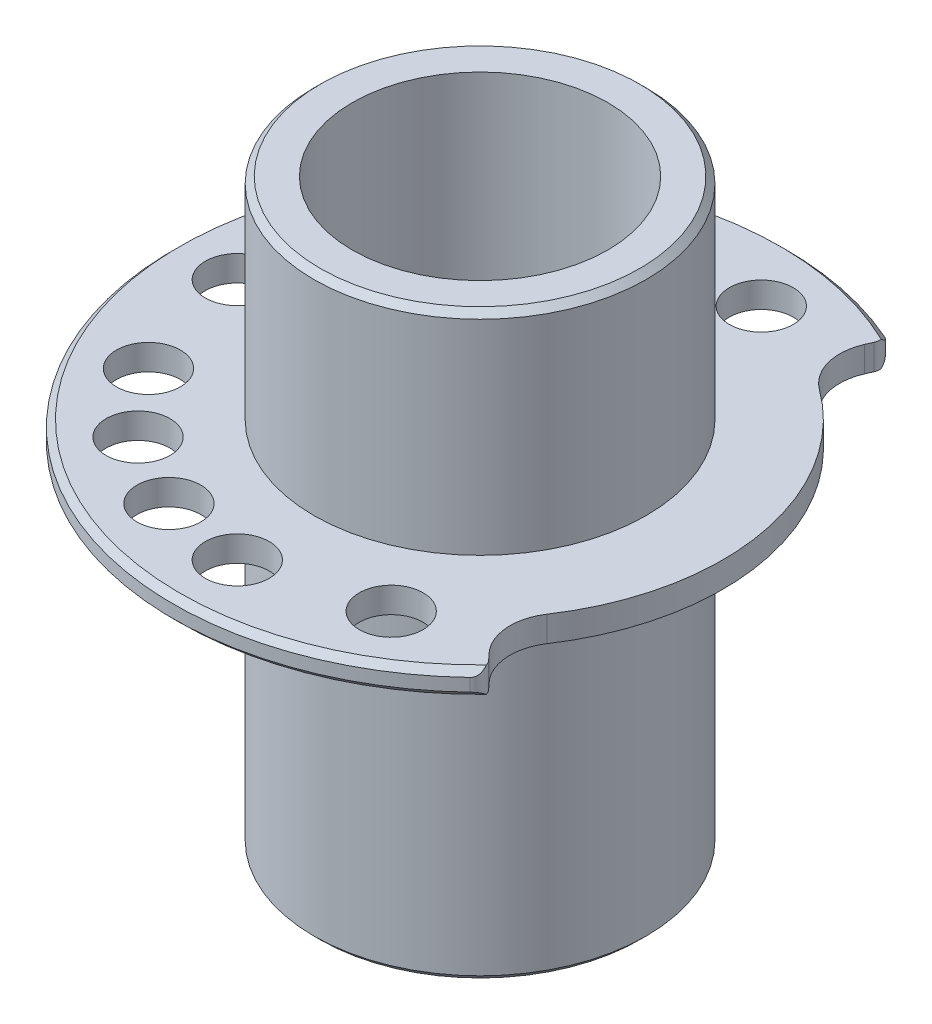
from build123d import *

# Parameters (mm, degrees)
SKETCH1_R                       = 13
BOSS_EXTRUDE1_DEPTH             = 28
SKETCH3_R                       = 24
BOSS_EXTRUDE2_DEPTH             = 1
SKETCH2_R                       = 10
CUT_EXTRUDE1_DEPTH              = 1
CUT_EXTRUDE1_DEPTH_BACK         = 30
SKETCH9_R                       = 13
BOSS_EXTRUDE3_DEPTH             = 17.5
CHAMFER2_SIZE                   = 0.5
CHAMFER3_SIZE                   = 0.5
CHAMFER4_SIZE                   = 0.5
SKETCH11_R                      = 10
CUT_EXTRUDE5_DEPTH              = 1
CUT_EXTRUDE5_DEPTH_BACK         = 46.5
CHAMFER5_SIZE                   = 0.5
SKETCH7_R                       = 2.5
WYTNIJ_WYCI_GNI_CIE1_DEPTH      = 28
WYTNIJ_WYCI_GNI_CIE1_DEPTH_BACK = 19.5
WYTNIJ_WYCI_GNI_CIE2_DEPTH      = 10
ZAOKR_GLENIE1_R                 = 4
ZAOKR_GLENIE2_R                 = 1


with BuildPart() as part:
    # Sketch1 → Boss-Extrude1 (new body)
    with BuildSketch(Plane(origin=(0, 0, 0), x_dir=(1, 0, 0), z_dir=(0, 1, 0))):
        Circle(SKETCH1_R)
    extrude(amount=-BOSS_EXTRUDE1_DEPTH)

    # Sketch3 → Boss-Extrude2 (add, symmetric)
    with BuildSketch(Plane(origin=(0, 0, 0), x_dir=(1, 0, 0), z_dir=(0, 1, 0))):
        Circle(SKETCH3_R)
    extrude(amount=BOSS_EXTRUDE2_DEPTH, both=True)

    # Sketch2 → Cut-Extrude1 (cut, two sides)
    with BuildSketch(Plane(origin=(0, -28, 0), x_dir=(-1, 0, 0), z_dir=(0, -1, 0))) as cut_extrude1_sk:
        Circle(SKETCH2_R)
    extrude(amount=CUT_EXTRUDE1_DEPTH, mode=Mode.SUBTRACT)
    extrude(cut_extrude1_sk.sketch, amount=-CUT_EXTRUDE1_DEPTH_BACK, mode=Mode.SUBTRACT)

    # Sketch9 → Boss-Extrude3 (add)
    with BuildSketch(Plane(origin=(0, 0, 0), x_dir=(1, 0, 0), z_dir=(0, 1, 0))):
        Circle(SKETCH9_R)
    extrude(amount=BOSS_EXTRUDE3_DEPTH)

    # Chamfer2
    chamfer2_edges = [part.edges().sort_by_distance(p)[0] for p in [
        (-24, -1, 0),
    ]]
    chamfer(chamfer2_edges, length=CHAMFER2_SIZE)

    # Chamfer3
    chamfer3_edges = [part.edges().sort_by_distance(p)[0] for p in [
        (-24, 1, 0),
    ]]
    chamfer(chamfer3_edges, length=CHAMFER3_SIZE)

    # Chamfer4
    chamfer4_edges = [part.edges().sort_by_distance(p)[0] for p in [
        (-13, -28, 0),
    ]]
    chamfer(chamfer4_edges, length=CHAMFER4_SIZE)

    # Sketch11 → Cut-Extrude5 (cut, two sides)
    with BuildSketch(Plane(origin=(0, 17.5, 0), x_dir=(1, 0, 0), z_dir=(0, 1, 0))) as cut_extrude5_sk:
        Circle(SKETCH11_R)
    extrude(amount=CUT_EXTRUDE5_DEPTH, mode=Mode.SUBTRACT)
    extrude(cut_extrude5_sk.sketch, amount=-CUT_EXTRUDE5_DEPTH_BACK, mode=Mode.SUBTRACT)

    # Chamfer5
    chamfer5_edges = [part.edges().sort_by_distance(p)[0] for p in [
        (-13, 17.5, 0),
    ]]
    chamfer(chamfer5_edges, length=CHAMFER5_SIZE)

    # Sketch7 → Wytnij-wyciągnięcie1 (cut, two sides)
    with BuildSketch(Plane.XZ.offset(1)) as wytnij_wyci_gni_cie1_sk:
        with Locations((0, 19)):
            Circle(SKETCH7_R)
        with Locations((3.299315376, -18.711347307)):
            Circle(SKETCH7_R)
        with Locations((-6.497936067, 17.852932618)):
            Circle(SKETCH7_R)
        with Locations((9.5, 16.454482672)):
            Circle(SKETCH7_R)
        with Locations((-19, 0)):
            Circle(SKETCH7_R)
        with Locations((-8.029746973, -17.219847954)):
            Circle(SKETCH7_R)
        with Locations((-12.212964584, 14.554844419)):
            Circle(SKETCH7_R)
        with Locations((-14.575405337, -12.230217242)):
            Circle(SKETCH7_R)
        with Locations((-16.454482672, 9.5)):
            Circle(SKETCH7_R)
    extrude(amount=WYTNIJ_WYCI_GNI_CIE1_DEPTH, mode=Mode.SUBTRACT)
    extrude(wytnij_wyci_gni_cie1_sk.sketch, amount=-WYTNIJ_WYCI_GNI_CIE1_DEPTH_BACK, mode=Mode.SUBTRACT)

    # Szkic1 → Wytnij-wyciągnięcie2 (cut)
    with BuildSketch(Plane(origin=(0, 1, 0), x_dir=(1, 0, 0), z_dir=(0, 1, 0))):
        with BuildLine():
            Line((13.831592317, -13.026398351), (17.289813207, -16.645190274))
            ThreePointArc((17.289813207, -16.645190274), (23.635386072, 4.167556264), (10.554119522, 21.554826863))
            Line((10.554119522, 21.554826863), (8.542154603, 16.971493592))
            ThreePointArc((8.542154603, 16.971493592), (18.711347307, 3.299315376), (13.831592317, -13.026398351))
        make_face()
    extrude(amount=-WYTNIJ_WYCI_GNI_CIE2_DEPTH, mode=Mode.SUBTRACT)

    # Zaokrąglenie1
    zaokr_glenie1_edges = [part.edges().sort_by_distance(p)[0] for p in [
        (13.831592317, 0, 13.026398351),
        (8.542154603, 0, -16.971493592),
    ]]
    fillet(zaokr_glenie1_edges, radius=ZAOKR_GLENIE1_R)

    # Zaokrąglenie2
    zaokr_glenie2_edges = [part.edges().sort_by_distance(p)[0] for p in [
        (10.554119522, 0, -21.554826863),
        (17.289813207, 0, 16.645190274),
    ]]
    fillet(zaokr_glenie2_edges, radius=ZAOKR_GLENIE2_R)


solid = part.part
